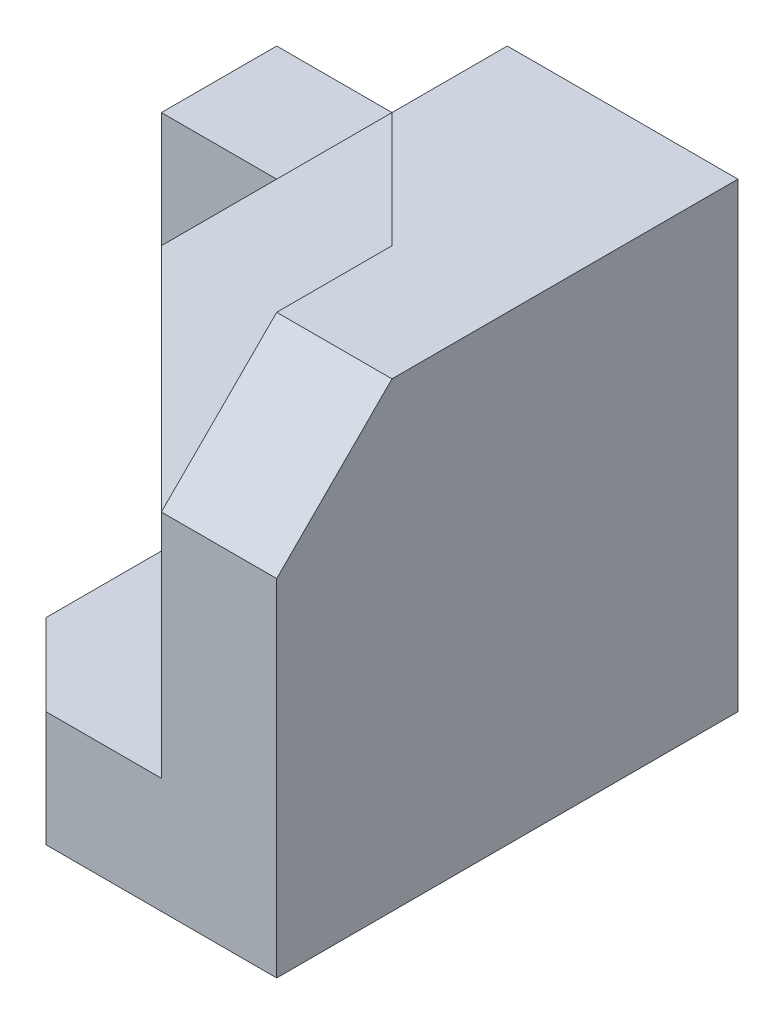
from build123d import *

# Parameters (mm, degrees)
BOSS_EXTRUDE1_DEPTH = 20
SKETCH3_W           = 5
SKETCH3_H           = 20
BOSS_EXTRUDE2_DEPTH = 5
CUT_EXTRUDE1_DEPTH  = 5
SKETCH5_W           = 5
SKETCH5_H           = 20
BOSS_EXTRUDE3_DEPTH = 5
CUT_EXTRUDE2_DEPTH  = 5
SKETCH7_W           = 5
SKETCH7_H           = 15
BOSS_EXTRUDE4_DEPTH = 5
BOSS_EXTRUDE6_DEPTH = 20
CUT_EXTRUDE4_DEPTH  = 31
BOSS_EXTRUDE7_DEPTH = 5


with BuildPart() as part:
    # Sketch2 → Boss-Extrude1 (new body)
    with BuildSketch(Plane(origin=(0, 0, 0), x_dir=(1, 0, 0), z_dir=(0, 1, 0))):
        Polygon((0, 0), (10, 0), (10, -15), (5, -15), (5, -10), (0, -5), align=None)
    extrude(amount=BOSS_EXTRUDE1_DEPTH)

    # Sketch3 → Boss-Extrude2 (add)
    with BuildSketch(Plane.XY.offset(15)):
        with Locations((7.5, 10)):
            Rectangle(SKETCH3_W, SKETCH3_H)
    extrude(amount=BOSS_EXTRUDE2_DEPTH)

    # Sketch4 → Cut-Extrude1 (cut)
    with BuildSketch(Plane.ZY.offset(-5)):
        Polygon((15, 20), (20, 15), (20, 20), align=None)
    extrude(amount=-CUT_EXTRUDE1_DEPTH, mode=Mode.SUBTRACT)

    # Sketch5 → Boss-Extrude3 (add)
    with BuildSketch(Plane.ZY):
        with Locations((2.5, 10)):
            Rectangle(SKETCH5_W, SKETCH5_H)
    extrude(amount=BOSS_EXTRUDE3_DEPTH)

    # Sketch6 → Cut-Extrude2 (cut)
    with BuildSketch(Plane.XY.offset(5)):
        Polygon((0, 20), (-5, 20), (-5, 15), align=None)
    extrude(amount=-CUT_EXTRUDE2_DEPTH, mode=Mode.SUBTRACT)

    # Sketch7 → Boss-Extrude4 (add)
    with BuildSketch(Plane.ZY.offset(5)):
        with Locations((2.5, 7.5)):
            Rectangle(SKETCH7_W, SKETCH7_H)
    extrude(amount=BOSS_EXTRUDE4_DEPTH)

    # Sketch8 → Boss-Extrude6 (add)
    with BuildSketch(Plane(origin=(0, 0, 0), x_dir=(-1, 0, 0), z_dir=(0, -1, 0))):
        Polygon((10, -5), (0, -5), (-5, -10), (-5, -15), (0, -15), align=None)
    extrude(amount=-BOSS_EXTRUDE6_DEPTH)

    # 3DSketch2 → Cut-Extrude4 (cut, along a direction that is not the sketch's normal)
    with BuildSketch(Plane(origin=(0, 20, 5), x_dir=(-0.7071067811865475, -0.7071067811865476, 0), z_dir=(-0.5773502691896257, 0.5773502691896257, 0.5773502691896257))):
        Polygon((0, 0), (-3.535533906, 6.123724357), (0, 12.247448714), (7.071067812, 12.247448714), (14.142135624, 0), align=None)
    extrude(amount=CUT_EXTRUDE4_DEPTH, dir=(0, 1, 0), mode=Mode.SUBTRACT)

    # Sketch9 → Boss-Extrude7 (add)
    with BuildSketch(Plane(origin=(0, 0, 0), x_dir=(-1, 0, 0), z_dir=(0, -1, 0))):
        Polygon((0, -15), (-5, -15), (-5, -20), (0, -20), (3.535533906, -16.464466094), (3.535533906, -11.464466094), align=None)
    extrude(amount=-BOSS_EXTRUDE7_DEPTH)


solid = part.part
